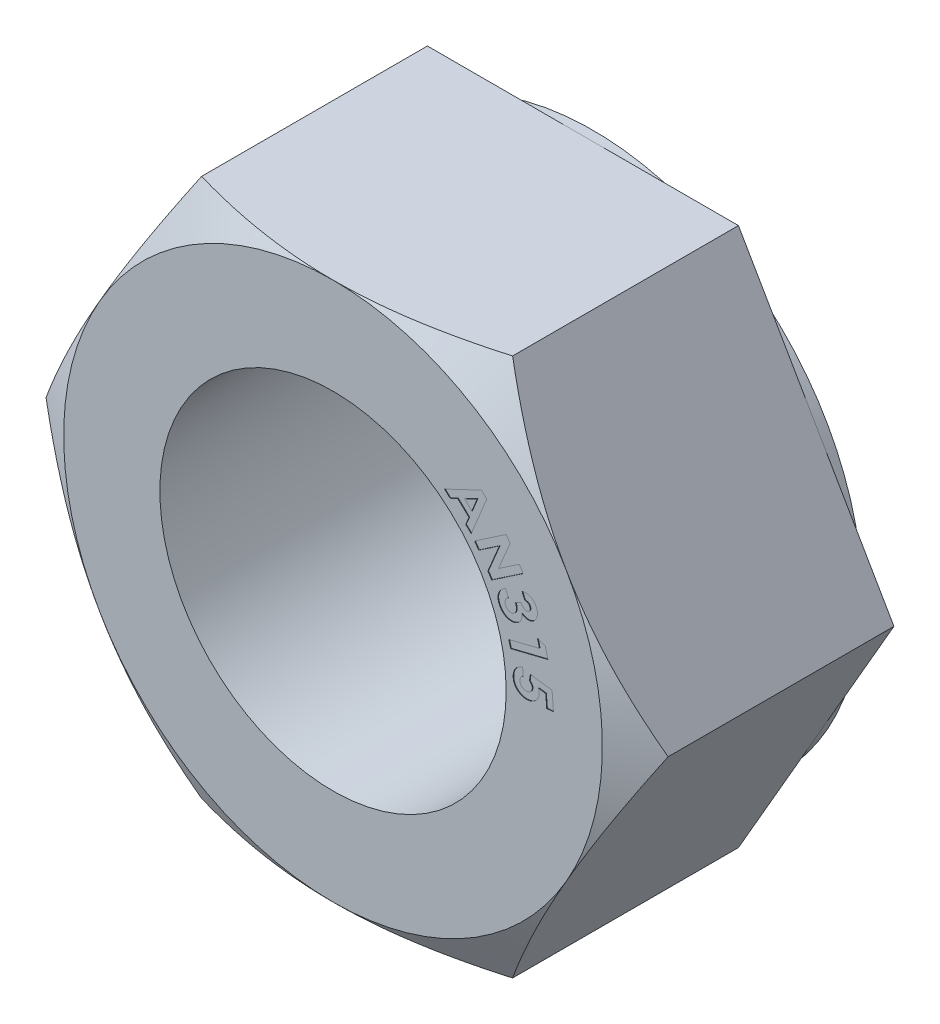
from build123d import *

# Parameters (mm, degrees)
SKETCH1_R           = 7.14375
BOSS_EXTRUDE1_DEPTH = 10.715625
SKETCH2_OUTSIDE_W   = 47.158
SKETCH2_OUTSIDE_H   = 43.72
SKETCH2_OUTSIDE_R   = 11.1125
CUT_EXTRUDE1_DEPTH  = 3.571875
CUT_EXTRUDE1_TAPER  = 60
CUT_EXTRUDE2_DEPTH  = 0.0254
SKETCH6_R           = 12.831609733
SKETCH6_R_2         = 11.1125
CUT_EXTRUDE4_DEPTH  = 0.4064


with BuildPart() as part:
    # Sketch1 → Boss-Extrude1 (new body)
    with BuildSketch(Plane.XY):
        Polygon((6.415804866, 11.1125), (-6.415804866, 11.1125), (-12.831609733, 0), (-6.415804866, -11.1125), (6.415804866, -11.1125), (12.831609733, 0), align=None)
        Circle(SKETCH1_R, mode=Mode.SUBTRACT)
    extrude(amount=BOSS_EXTRUDE1_DEPTH)

    # Sketch2 outside → Cut-Extrude1 (cut)
    with BuildSketch(Plane.XY.offset(10.715625)):
        Rectangle(SKETCH2_OUTSIDE_W, SKETCH2_OUTSIDE_H)
        Circle(SKETCH2_OUTSIDE_R, mode=Mode.SUBTRACT)
    extrude(amount=-CUT_EXTRUDE1_DEPTH, taper=CUT_EXTRUDE1_TAPER, mode=Mode.SUBTRACT)

    # Sketch4 → Cut-Extrude2 (cut)
    with BuildSketch(Plane.XY.offset(10.715625)):
        with BuildLine():
            Line((9.034637176, 0.97406133), (9.094104825, 0.234372829))
            Line((9.094104825, 0.234372829), (8.817119148, 0.212112212))
            Line((8.817119148, 0.212112212), (8.775778002, 0.727286491))
            Line((8.775778002, 0.727286491), (8.482573875, 0.768627636))
            add(Edge.make_bspline(
                [(8.482573875, 0.768627636), (8.485703044, 0.759984015), (8.491854097, 0.742993119), (8.49814037, 0.717232268), (8.503691053, 0.692389646), (8.505312072, 0.675900238), (8.506106527, 0.667818842)],
                knots=[0, 0, 0, 0, 2.7555e-05, 5.4165e-05, 7.9487e-05, 0.000103824, 0.000103824, 0.000103824, 0.000103824], degree=3))
            add(Edge.make_bspline(
                [(8.506106527, 0.667818842), (8.507083937, 0.650226592), (8.5090043, 0.615662233), (8.506006277, 0.564623413), (8.498377399, 0.515517161), (8.485999247, 0.468266076), (8.468634329, 0.422955617), (8.447011609, 0.379295192), (8.420010067, 0.33787329), (8.388716616, 0.298666207), (8.353568588, 0.262545635), (8.315221861, 0.230272216), (8.274089298, 0.20205309), (8.22969648, 0.178538286), (8.182694722, 0.158535772), (8.132315576, 0.143980445), (8.079443344, 0.132403831), (8.042929006, 0.128748446), (8.024323174, 0.126885849)],
                knots=[0, 0, 0, 0, 5.2824e-05, 0.000103786, 0.000153036, 0.000201708, 0.00025002, 0.000298374, 0.000347595, 0.000398054, 0.000448654, 0.000498532, 0.000548192, 0.000597988, 0.000649016, 0.000701133, 0.000755083, 0.000811134, 0.000811134, 0.000811134, 0.000811134], degree=3))
            add(Edge.make_bspline(
                [(8.024323174, 0.126885849), (8.005460968, 0.125927887), (7.968252022, 0.124038141), (7.913139116, 0.126800589), (7.859964079, 0.135336032), (7.808464114, 0.148119867), (7.759065608, 0.166888777), (7.711206766, 0.190152488), (7.665522445, 0.218914608), (7.622056885, 0.252201696), (7.582139175, 0.289274565), (7.546409825, 0.329387215), (7.515566149, 0.372037012), (7.489179094, 0.417222836), (7.467819245, 0.464986344), (7.451723954, 0.515384983), (7.439602429, 0.568029945), (7.43574119, 0.60426483), (7.433780806, 0.622661591)],
                knots=[0, 0, 0, 0, 5.6638e-05, 0.000111728, 0.000165161, 0.000217994, 0.000270623, 0.000323388, 0.00037739, 0.000432281, 0.00048741, 0.000540572, 0.000593178, 0.000645049, 0.000697292, 0.000749788, 0.000803562, 0.000859021, 0.000859021, 0.000859021, 0.000859021], degree=3))
            add(Edge.make_bspline(
                [(7.433780806, 0.622661591), (7.432756709, 0.639192918), (7.430735237, 0.671824206), (7.432622913, 0.720198081), (7.437374457, 0.767169571), (7.446870671, 0.812528702), (7.459549597, 0.856460302), (7.475682194, 0.899085767), (7.496283988, 0.93977543), (7.520100153, 0.978988698), (7.547248726, 1.015904919), (7.577439956, 1.050296362), (7.61044537, 1.081812949), (7.64665182, 1.110176315), (7.685638777, 1.135818215), (7.727688391, 1.158186378), (7.772440331, 1.178264516), (7.803842167, 1.18877012), (7.819843507, 1.19412343)],
                knots=[0, 0, 0, 0, 4.9659e-05, 9.8023e-05, 0.000145046, 0.000191136, 0.000236827, 0.000282125, 0.000327635, 0.000373448, 0.000419625, 0.000464918, 0.000510579, 0.000556322, 0.000602716, 0.00065038, 0.000699072, 0.000749663, 0.000749663, 0.000749663, 0.000749663], degree=3))
            Line((7.819843507, 1.19412343), (7.845284212, 0.878658686))
            add(Edge.make_bspline(
                [(7.845284212, 0.878658686), (7.833920906, 0.871446913), (7.811888861, 0.857464178), (7.783474643, 0.831796306), (7.759053259, 0.804369367), (7.74005204, 0.774085035), (7.725929701, 0.74200122), (7.716657581, 0.708596335), (7.711974469, 0.673985671), (7.712862365, 0.650656209), (7.713310554, 0.63888004)],
                knots=[0, 0, 0, 0, 4.0308e-05, 7.8153e-05, 0.00011444, 0.000150172, 0.000184915, 0.00021925, 0.000253882, 0.000289183, 0.000289183, 0.000289183, 0.000289183], degree=3))
            add(Edge.make_bspline(
                [(7.713310554, 0.63888004), (7.714189359, 0.630687795), (7.715916485, 0.614587467), (7.721591386, 0.591229013), (7.728737381, 0.568875701), (7.738354445, 0.547753355), (7.750274068, 0.527870353), (7.764353154, 0.50902516), (7.780576647, 0.491276085), (7.798718998, 0.474709543), (7.818448348, 0.459856463), (7.839731536, 0.447530318), (7.861755024, 0.436651302), (7.885270242, 0.428992978), (7.909716851, 0.423132489), (7.935168511, 0.419606857), (7.961790665, 0.418783824), (7.979805237, 0.419647824), (7.989024196, 0.420089976)],
                knots=[0, 0, 0, 0, 2.4692e-05, 4.8528e-05, 7.196e-05, 9.5015e-05, 0.000117975, 0.000141381, 0.000165468, 0.000190004, 0.000214999, 0.000239379, 0.000263702, 0.000288541, 0.000313378, 0.000339058, 0.00036547, 0.000393153, 0.000393153, 0.000393153, 0.000393153], degree=3))
            add(Edge.make_bspline(
                [(7.989024196, 0.420089976), (7.997949518, 0.42100209), (8.015482705, 0.422793876), (8.040903715, 0.427946242), (8.06503572, 0.434860003), (8.087506485, 0.444181261), (8.108740689, 0.455029351), (8.128654206, 0.467796734), (8.146962761, 0.482764907), (8.163903117, 0.499356803), (8.178917974, 0.517147574), (8.19183153, 0.535933916), (8.202754243, 0.555194853), (8.211006215, 0.575434146), (8.217115386, 0.596211755), (8.220928104, 0.617746682), (8.222589061, 0.639924811), (8.221856915, 0.654886717), (8.221488639, 0.662412692)],
                knots=[0, 0, 0, 0, 2.6901e-05, 5.2846e-05, 7.7701e-05, 0.000102091, 0.000125701, 0.000149165, 0.000172905, 0.000196517, 0.000220214, 0.00024262, 0.000264828, 0.000286502, 0.000308037, 0.000329683, 0.000352, 0.000374588, 0.000374588, 0.000374588, 0.000374588], degree=3))
            add(Edge.make_bspline(
                [(8.221488639, 0.662412692), (8.220548591, 0.670615789), (8.218667255, 0.687032821), (8.211701337, 0.711167051), (8.201691189, 0.734746461), (8.189008937, 0.758121661), (8.172815156, 0.780702216), (8.153949442, 0.803085227), (8.13201605, 0.825113453), (8.115506601, 0.838627198), (8.107005466, 0.845585769)],
                knots=[0, 0, 0, 0, 2.4735e-05, 4.9503e-05, 7.5017e-05, 0.000101489, 0.000129104, 0.000158217, 0.000189249, 0.00022219, 0.00022219, 0.00022219, 0.00022219], degree=3))
            Line((8.107005466, 0.845585769), (8.142304444, 1.094586671))
            Line((8.142304444, 1.094586671), (9.034637176, 0.97406133))
        make_face()
        Polygon((8.754925158, 2.424975805), (8.863048155, 1.987713685), (7.32801961, 1.608011161), (7.256149618, 1.898353208), (8.516736557, 2.210319855), (8.438506388, 2.526420616), align=None)
        with BuildLine():
            Line((7.913386635, 3.622444587), (7.795087356, 3.88702792))
            add(Edge.make_bspline(
                [(7.795087356, 3.88702792), (7.809030328, 3.890939092), (7.836389311, 3.898613616), (7.877544877, 3.906500027), (7.917712046, 3.911369505), (7.956952522, 3.912995856), (7.995254722, 3.911450623), (8.032589426, 3.906637244), (8.069054107, 3.898843752), (8.092490101, 3.890962905), (8.104191923, 3.88702792)],
                knots=[0, 0, 0, 0, 4.3428e-05, 8.5214e-05, 0.000125566, 0.000164714, 0.000202908, 0.000240419, 0.000277534, 0.000314546, 0.000314546, 0.000314546, 0.000314546], degree=3))
            add(Edge.make_bspline(
                [(8.104191923, 3.88702792), (8.120026858, 3.880782247), (8.151361385, 3.868423167), (8.195385003, 3.844348147), (8.235970944, 3.816155881), (8.273473171, 3.784191269), (8.307573067, 3.748143505), (8.338218794, 3.707997526), (8.365889475, 3.664047887), (8.380867305, 3.632264047), (8.388491803, 3.61608441)],
                knots=[0, 0, 0, 0, 5.1028e-05, 0.000100976, 0.000150111, 0.000199057, 0.000248546, 0.000298667, 0.000350376, 0.000403993, 0.000403993, 0.000403993, 0.000403993], degree=3))
            add(Edge.make_bspline(
                [(8.388491803, 3.61608441), (8.394700896, 3.601346486), (8.406889394, 3.572415826), (8.420220236, 3.527973589), (8.429144067, 3.483893344), (8.4341211, 3.4400395), (8.43428691, 3.39625822), (8.430610127, 3.352674266), (8.422202942, 3.309314124), (8.409412651, 3.266849887), (8.393614974, 3.225811661), (8.373895225, 3.187756866), (8.351861583, 3.152511501), (8.326035745, 3.120899419), (8.297716796, 3.092119127), (8.266390489, 3.066451456), (8.231705391, 3.04432513), (8.206828331, 3.032292023), (8.194188418, 3.02617806)],
                knots=[0, 0, 0, 0, 4.7951e-05, 9.4128e-05, 0.000138907, 0.000182735, 0.000226303, 0.000270037, 0.000313757, 0.000358533, 0.000402942, 0.000445467, 0.000486931, 0.000527408, 0.000567659, 0.00060789, 0.000648646, 0.000690743, 0.000690743, 0.000690743, 0.000690743], degree=3))
            add(Edge.make_bspline(
                [(8.194188418, 3.02617806), (8.178135412, 3.01972117), (8.146488312, 3.006991973), (8.096264583, 2.99703305), (8.045404384, 2.994023487), (7.993953412, 2.998916124), (7.942744835, 3.011426522), (7.89250085, 3.031769131), (7.843274804, 3.059669021), (7.812929519, 3.083328492), (7.797313418, 3.095503982)],
                knots=[0, 0, 0, 0, 5.1812e-05, 0.000102143, 0.000152787, 0.000204208, 0.00025658, 0.000310377, 0.000366348, 0.00042569, 0.00042569, 0.00042569, 0.00042569], degree=3))
            add(Edge.make_bspline(
                [(7.797313418, 3.095503982), (7.798659121, 3.083220784), (7.801310329, 3.059021299), (7.802137589, 3.022987548), (7.800755766, 2.987988556), (7.796121143, 2.953987702), (7.789264503, 2.920986971), (7.779524098, 2.888924709), (7.767650141, 2.857709582), (7.752475097, 2.827898001), (7.73549848, 2.799245507), (7.71597038, 2.772552772), (7.694530763, 2.747418378), (7.670678173, 2.724348359), (7.644837837, 2.70298365), (7.616973236, 2.683354132), (7.586714524, 2.665974845), (7.565446551, 2.655776098), (7.554672693, 2.650609651)],
                knots=[0, 0, 0, 0, 3.7055e-05, 7.3002e-05, 0.000108019, 0.000142021, 0.000175826, 0.000209027, 0.000242453, 0.000275874, 0.000309251, 0.000342264, 0.000374964, 0.000408247, 0.000441676, 0.000475465, 0.000510374, 0.000546213, 0.000546213, 0.000546213, 0.000546213], degree=3))
            add(Edge.make_bspline(
                [(7.554672693, 2.650609651), (7.53857259, 2.643925321), (7.506782051, 2.630726744), (7.457522762, 2.616758723), (7.408180445, 2.60810337), (7.358591017, 2.604836175), (7.309032449, 2.607185377), (7.259248009, 2.614516374), (7.209410658, 2.62742042), (7.159921361, 2.645462726), (7.111770077, 2.66812487), (7.066375127, 2.695628335), (7.024146104, 2.727576327), (6.98528403, 2.764139234), (6.949215501, 2.804616441), (6.916249651, 2.849491721), (6.886621133, 2.898832814), (6.869916237, 2.934120596), (6.861413478, 2.952082006)],
                knots=[0, 0, 0, 0, 5.2263e-05, 0.000103196, 0.00015323, 0.000202306, 0.000251965, 0.000301796, 0.000353011, 0.000406127, 0.000459613, 0.000512406, 0.000565069, 0.000618168, 0.000672227, 0.0007275, 0.000784983, 0.000844573, 0.000844573, 0.000844573, 0.000844573], degree=3))
            add(Edge.make_bspline(
                [(6.861413478, 2.952082006), (6.854102296, 2.969347662), (6.839739904, 3.003265041), (6.823976901, 3.055181553), (6.813050886, 3.106460505), (6.806724526, 3.157018439), (6.806319101, 3.206992113), (6.810171505, 3.256279655), (6.820066467, 3.304781312), (6.834141893, 3.352526641), (6.853694722, 3.398572896), (6.877557641, 3.442622107), (6.906022591, 3.484265949), (6.939313502, 3.523137846), (6.9771399, 3.55949714), (7.019281554, 3.593661672), (7.066128995, 3.625244423), (7.099865335, 3.643600188), (7.117092564, 3.652973433)],
                knots=[0, 0, 0, 0, 5.6218e-05, 0.000110438, 0.000162455, 0.000213378, 0.000262992, 0.000312139, 0.000361409, 0.000411211, 0.000461236, 0.000511184, 0.000561285, 0.000612266, 0.000664443, 0.000718479, 0.000774839, 0.000833651, 0.000833651, 0.000833651, 0.000833651], degree=3))
            Line((7.117092564, 3.652973433), (7.23888994, 3.380439879))
            add(Edge.make_bspline(
                [(7.23888994, 3.380439879), (7.230544647, 3.374823243), (7.214244773, 3.363852932), (7.191757683, 3.346057878), (7.171518711, 3.327837623), (7.153628275, 3.309128283), (7.138226611, 3.289680868), (7.125537465, 3.269536625), (7.114885089, 3.249049941), (7.103851717, 3.221310584), (7.096402144, 3.184999377), (7.095252431, 3.140338075), (7.103501074, 3.094694802), (7.114982448, 3.065444537), (7.12090867, 3.05034673)],
                knots=[0, 0, 0, 0, 3.0169e-05, 5.8925e-05, 8.5943e-05, 0.000111812, 0.000136496, 0.000160227, 0.000183126, 0.000205685, 0.000249595, 0.000293491, 0.000339029, 0.00038761, 0.00038761, 0.00038761, 0.00038761], degree=3))
            add(Edge.make_bspline(
                [(7.12090867, 3.05034673), (7.124576801, 3.042530375), (7.131784859, 3.027170851), (7.144968992, 3.005812116), (7.159476975, 2.986349832), (7.175788184, 2.969126012), (7.192727858, 2.952872767), (7.212018188, 2.939395235), (7.232423939, 2.927524259), (7.261065989, 2.91449593), (7.298474242, 2.903518763), (7.344437475, 2.900047375), (7.39053167, 2.905527967), (7.419384057, 2.91675996), (7.434147352, 2.922507187)],
                knots=[0, 0, 0, 0, 2.5884e-05, 5.0863e-05, 7.5159e-05, 9.8563e-05, 0.000121966, 0.000145441, 0.00016895, 0.000192715, 0.000239717, 0.00028501, 0.000330213, 0.000377579, 0.000377579, 0.000377579, 0.000377579], degree=3))
            add(Edge.make_bspline(
                [(7.434147352, 2.922507187), (7.442097627, 2.926344231), (7.457761429, 2.933904059), (7.479180008, 2.948429101), (7.498553222, 2.965142228), (7.515626824, 2.984253932), (7.530748122, 3.005427594), (7.543606566, 3.028893512), (7.553854723, 3.054732077), (7.562599742, 3.082505279), (7.568735375, 3.112205938), (7.571013215, 3.143586303), (7.570752698, 3.176363305), (7.5671859, 3.210526119), (7.560334534, 3.246226807), (7.550341476, 3.283233522), (7.537801402, 3.321944794), (7.526893103, 3.347551165), (7.521281767, 3.360723333)],
                knots=[0, 0, 0, 0, 2.6454e-05, 5.212e-05, 7.737e-05, 0.00010304, 0.000128806, 0.000155278, 0.000183092, 0.00021206, 0.000242558, 0.000273826, 0.000306265, 0.000340787, 0.000376713, 0.000415203, 0.000455731, 0.000498663, 0.000498663, 0.000498663, 0.000498663], degree=3))
            Line((7.521281767, 3.360723333), (7.757562316, 3.466302259))
            add(Edge.make_bspline(
                [(7.757562316, 3.466302259), (7.76595631, 3.451348028), (7.781647867, 3.423392903), (7.806397231, 3.385987372), (7.830202333, 3.355746375), (7.853390061, 3.331985448), (7.87717836, 3.31439841), (7.901071141, 3.300425633), (7.926202171, 3.290549945), (7.951855557, 3.284115448), (7.977581153, 3.281608634), (8.002699881, 3.28258939), (8.027095277, 3.286722134), (8.042263968, 3.292816683), (8.049812416, 3.295849535)],
                knots=[0, 0, 0, 0, 5.1436e-05, 9.6153e-05, 0.000134395, 0.000166776, 0.000195397, 0.000222889, 0.000249581, 0.000276113, 0.000301997, 0.00032682, 0.000351396, 0.000375739, 0.000375739, 0.000375739, 0.000375739], degree=3))
            add(Edge.make_bspline(
                [(8.049812416, 3.295849535), (8.059041153, 3.300584553), (8.077119421, 3.30986003), (8.100072589, 3.329535447), (8.117634402, 3.353610499), (8.130388245, 3.380895603), (8.137305677, 3.410895272), (8.138363188, 3.442476199), (8.132400383, 3.474978612), (8.124072743, 3.495893808), (8.119774355, 3.506689378)],
                knots=[0, 0, 0, 0, 3.1043e-05, 6.081e-05, 8.9686e-05, 0.000119848, 0.000150549, 0.000181411, 0.000214036, 0.00024884, 0.00024884, 0.00024884, 0.00024884], degree=3))
            add(Edge.make_bspline(
                [(8.119774355, 3.506689378), (8.114972371, 3.51618424), (8.105523355, 3.53486758), (8.086377469, 3.559971893), (8.062746494, 3.580880508), (8.036172941, 3.598692526), (8.007140083, 3.612339505), (7.976646432, 3.621011275), (7.945139352, 3.624722619), (7.924092945, 3.623212688), (7.913386635, 3.622444587)],
                knots=[0, 0, 0, 0, 3.1877e-05, 6.2726e-05, 9.4022e-05, 0.000126126, 0.000158421, 0.000189828, 0.000220873, 0.000253017, 0.000253017, 0.000253017, 0.000253017], degree=3))
        make_face()
        Polygon((7.144381482, 5.594349003), (7.304975933, 5.357432436), (6.826690677, 4.2195969), (7.682770404, 4.799326968), (7.850361049, 4.551598102), (6.549386991, 3.670713686), (6.388474531, 3.908584279), (6.864851734, 5.043557737), (6.011316077, 4.465735722), (5.843407423, 4.713464588), align=None)
        Polygon((6.124200983, 6.669558529), (6.344263083, 6.460626738), (5.700613243, 4.903973593), (5.475144994, 5.117993525), (5.609026704, 5.437592383), (5.143779809, 5.878988617), (4.827997057, 5.732068545), (4.602210799, 5.946406486), align=None)
        Polygon((5.948660118, 6.261235212), (5.42521761, 6.013824354), (5.72828001, 5.726344386), align=None, mode=Mode.SUBTRACT)
    extrude(amount=-CUT_EXTRUDE2_DEPTH, mode=Mode.SUBTRACT)

    # Sketch6 → Cut-Extrude4 (cut)
    with BuildSketch(Plane(origin=(0, 0, 0), x_dir=(-1, 0, 0), z_dir=(0, 0, -1))):
        Circle(SKETCH6_R)
        Circle(SKETCH6_R_2, mode=Mode.SUBTRACT)
    extrude(amount=-CUT_EXTRUDE4_DEPTH, mode=Mode.SUBTRACT)


solid = part.part
